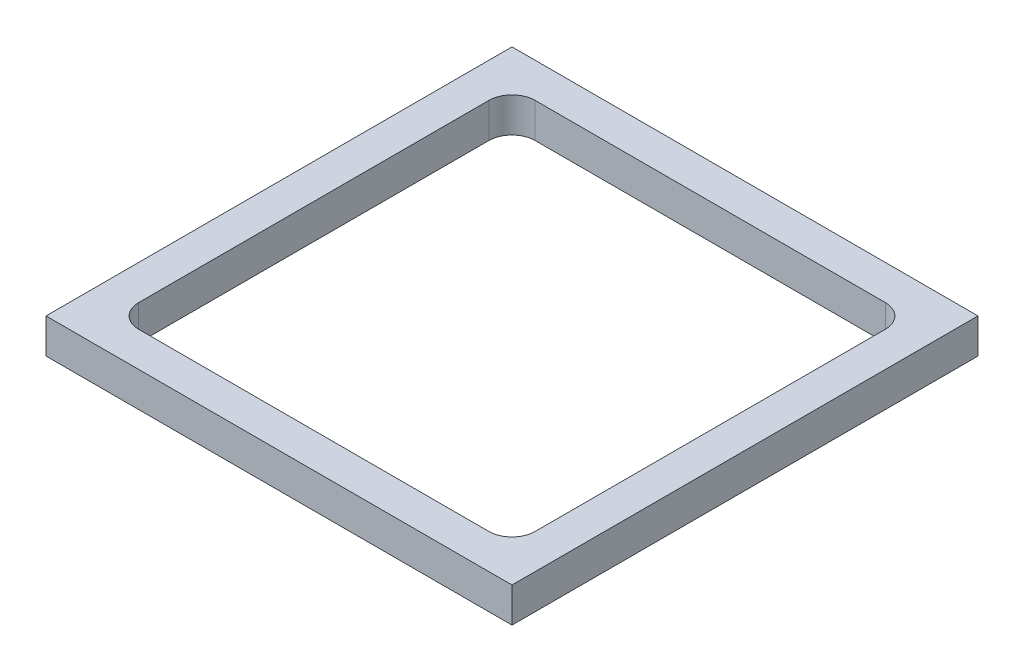
from build123d import *

# Parameters (mm, degrees)
SKETCH1_W           = 127.635
SKETCH1_H           = 127.635
BOSS_EXTRUDE1_DEPTH = 9.525
SKETCH5_W           = 108.585
SKETCH5_H           = 108.585
CUT_EXTRUDE1_DEPTH  = 9.525
FILLET1_R           = 6.35


with BuildPart() as part:
    # Sketch1 → Boss-Extrude1 (new body)
    with BuildSketch(Plane(origin=(0, 0, 0), x_dir=(1, 0, 0), z_dir=(0, 1, 0))):
        with Locations((63.8175, 63.8175)):
            Rectangle(SKETCH1_W, SKETCH1_H)
    extrude(amount=BOSS_EXTRUDE1_DEPTH)

    # Sketch5 → Cut-Extrude1 (cut)
    with BuildSketch(Plane(origin=(0, 9.525, 0), x_dir=(1, 0, 0), z_dir=(0, 1, 0))):
        with Locations((63.8175, 63.8175)):
            Rectangle(SKETCH5_W, SKETCH5_H)
    extrude(amount=-CUT_EXTRUDE1_DEPTH, mode=Mode.SUBTRACT)

    # Fillet1
    fillet1_edges = [part.edges().sort_by_distance(p)[0] for p in [
        (118.11, 4.7625, -9.525),
        (9.525, 4.7625, -9.525),
        (9.525, 4.7625, -118.11),
        (118.11, 4.7625, -118.11),
    ]]
    fillet(fillet1_edges, radius=FILLET1_R)


solid = part.part
